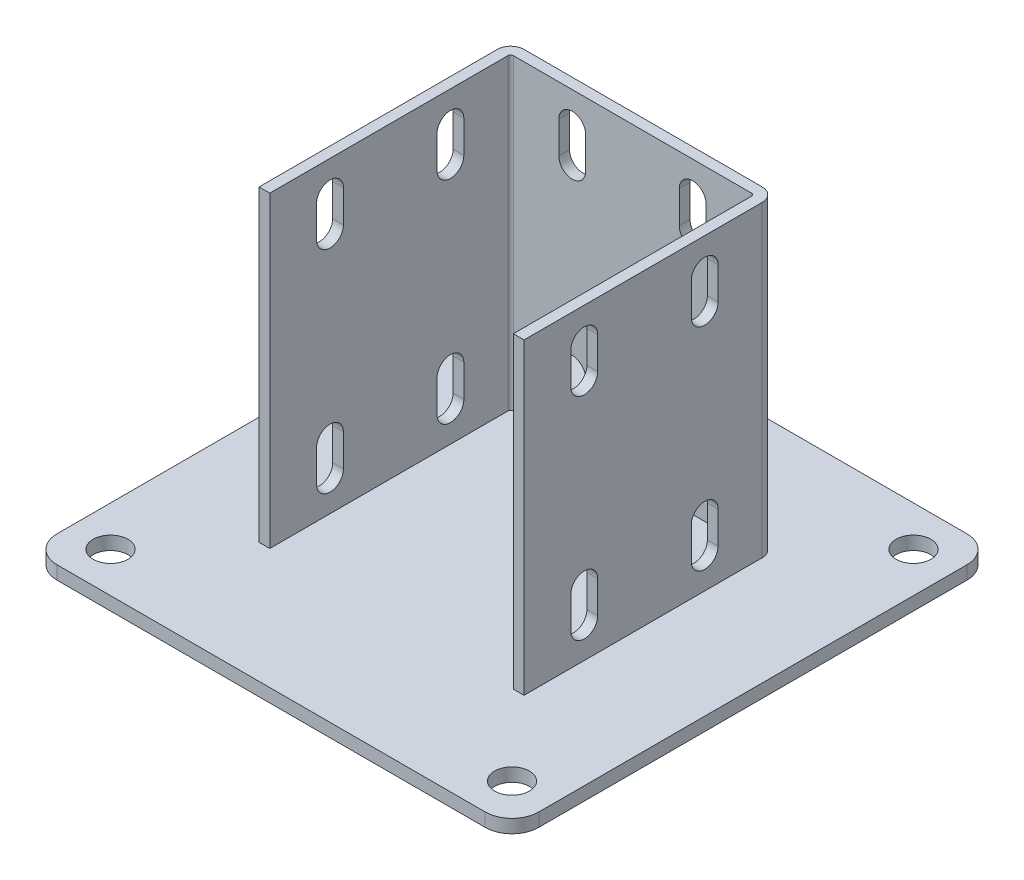
from build123d import *

# Parameters (mm, degrees)
SKETCH_2_W          = 180
SKETCH_2_H          = 180
EXTRUDE_1_DEPTH     = 5
EXTRUDE_1_2_DEPTH   = 115
EXTRUDE_2_DEPTH     = 2
CUT_EXTRUDE_1_DEPTH = 140.5
SKETCH_6_R          = 6.5
CUT_EXTRUDE_2_DEPTH = 6
FILLET_1_R          = 10
CUT_EXTRUDE_3_REACH = 141


with BuildPart() as part:
    # Эскиз2 → Extrude 1 (new body)
    with BuildSketch(Plane(origin=(0, 0, 0), x_dir=(1, 0, 0), z_dir=(0, 1, 0))):
        Rectangle(SKETCH_2_W, SKETCH_2_H)
    extrude(amount=EXTRUDE_1_DEPTH)

    # Эскиз3 → Extrude 1 2 (add)
    with BuildSketch(Plane(origin=(0, 5, 0), x_dir=(1, 0, 0), z_dir=(0, 1, 0))):
        with BuildLine():
            Line((-45.5, -45), (-45.5, 44))
            ThreePointArc((-45.5, 44), (-45.207106781, 44.707106781), (-44.5, 45))
            Line((-44.5, 45), (44.5, 45))
            ThreePointArc((44.5, 45), (45.207106781, 44.707106781), (45.5, 44))
            Line((45.5, 44), (45.5, -45))
            Line((45.5, -45), (49.5, -45))
            Line((49.5, -45), (49.5, 44))
            ThreePointArc((49.5, 44), (48.035533906, 47.535533906), (44.5, 49))
            Line((44.5, 49), (-44.5, 49))
            ThreePointArc((-44.5, 49), (-48.035533906, 47.535533906), (-49.5, 44))
            Line((-49.5, 44), (-49.5, -45))
            Line((-49.5, -45), (-45.5, -45))
        make_face()
    extrude(amount=EXTRUDE_1_2_DEPTH)

    # Эскиз4 → Бобышка-Вытянуть2 (add, symmetric)
    with BuildSketch(Plane(origin=(0, 0, 0), x_dir=(0, 0, -1), z_dir=(1, 0, 0))):
        Polygon((49, 67.353829072), (85, 5), (49, 5), align=None)
    extrude(amount=EXTRUDE_2_DEPTH, both=True)

    # Эскиз5 → Вырез-Вытянуть1 (cut, through all)
    with BuildSketch(Plane(origin=(49.5, 0, 0), x_dir=(0, 0, -1), z_dir=(1, 0, 0))):
        with BuildLine():
            Line((-17.5, 108), (-17.5, 96))
            ThreePointArc((-17.5, 96), (-22.5, 91), (-27.5, 96))
            Line((-27.5, 96), (-27.5, 108))
            ThreePointArc((-27.5, 108), (-22.5, 113), (-17.5, 108))
        make_face()
        with BuildLine():
            Line((-17.5, 29), (-17.5, 17))
            ThreePointArc((-17.5, 17), (-22.5, 12), (-27.5, 17))
            Line((-27.5, 17), (-27.5, 29))
            ThreePointArc((-27.5, 29), (-22.5, 34), (-17.5, 29))
        make_face()
        with BuildLine():
            Line((17.5, 108), (17.5, 96))
            ThreePointArc((17.5, 96), (22.5, 91), (27.5, 96))
            Line((27.5, 96), (27.5, 108))
            ThreePointArc((27.5, 108), (22.5, 113), (17.5, 108))
        make_face()
        with BuildLine():
            Line((17.5, 29), (17.5, 17))
            ThreePointArc((17.5, 17), (22.5, 12), (27.5, 17))
            Line((27.5, 17), (27.5, 29))
            ThreePointArc((27.5, 29), (22.5, 34), (17.5, 29))
        make_face()
    extrude(amount=-CUT_EXTRUDE_1_DEPTH, mode=Mode.SUBTRACT)

    # Эскиз6 → Вырез-Вытянуть2 (cut, through all)
    with BuildSketch(Plane(origin=(0, 5, 0), x_dir=(1, 0, 0), z_dir=(0, 1, 0))):
        with Locations(Location((-75, 75, 0), (0, 0, 270))):  # turned: the seam where the file's is
            Circle(SKETCH_6_R)
        with Locations(Location((-75, -75, 0), (0, 0, 270))):  # turned: the seam where the file's is
            Circle(SKETCH_6_R)
        with Locations(Location((75, 75, 0), (0, 0, 270))):  # turned: the seam where the file's is
            Circle(SKETCH_6_R)
        with Locations(Location((75, -75, 0), (0, 0, 270))):  # turned: the seam where the file's is
            Circle(SKETCH_6_R)
    extrude(amount=-CUT_EXTRUDE_2_DEPTH, mode=Mode.SUBTRACT)

    # Скругление1
    fillet_1_edges = [part.edges().sort_by_distance(p)[0] for p in [
        (90, 2.5, 90),
        (-90, 2.5, 90),
        (-90, 2.5, -90),
        (90, 2.5, -90),
    ]]
    fillet(fillet_1_edges, radius=FILLET_1_R)

    # Эскиз8 → Вырез-Вытянуть3 (cut, up to next)
    with BuildSketch(Plane(origin=(0, 0, -49), x_dir=(-1, 0, 0), z_dir=(0, 0, -1)), mode=Mode.PRIVATE) as cut_extrude_3_sk1:
        with BuildLine():
            Line((-17.5, 108), (-17.5, 96))
            ThreePointArc((-17.5, 96), (-22.5, 91), (-27.5, 96))
            Line((-27.5, 96), (-27.5, 108))
            ThreePointArc((-27.5, 108), (-22.5, 113), (-17.5, 108))
        make_face()
    cut_extrude_3_tool1 = extrude(cut_extrude_3_sk1.sketch, amount=-CUT_EXTRUDE_3_REACH, mode=Mode.PRIVATE) & part.part
    add(cut_extrude_3_tool1.solids().sort_by_distance((22.5, 102, -49))[0], mode=Mode.SUBTRACT)
    # Эскиз8 → Вырез-Вытянуть3 (cut, up to next)
    with BuildSketch(Plane(origin=(0, 0, -49), x_dir=(-1, 0, 0), z_dir=(0, 0, -1)), mode=Mode.PRIVATE) as cut_extrude_3_sk2:
        with BuildLine():
            Line((-17.5, 29), (-17.5, 17))
            ThreePointArc((-17.5, 17), (-22.5, 12), (-27.5, 17))
            Line((-27.5, 17), (-27.5, 29))
            ThreePointArc((-27.5, 29), (-22.5, 34), (-17.5, 29))
        make_face()
    cut_extrude_3_tool2 = extrude(cut_extrude_3_sk2.sketch, amount=-CUT_EXTRUDE_3_REACH, mode=Mode.PRIVATE) & part.part
    add(cut_extrude_3_tool2.solids().sort_by_distance((22.5, 23, -49))[0], mode=Mode.SUBTRACT)
    # Эскиз8 → Вырез-Вытянуть3 (cut, up to next)
    with BuildSketch(Plane(origin=(0, 0, -49), x_dir=(-1, 0, 0), z_dir=(0, 0, -1)), mode=Mode.PRIVATE) as cut_extrude_3_sk3:
        with BuildLine():
            Line((17.5, 108), (17.5, 96))
            ThreePointArc((17.5, 96), (22.5, 91), (27.5, 96))
            Line((27.5, 96), (27.5, 108))
            ThreePointArc((27.5, 108), (22.5, 113), (17.5, 108))
        make_face()
    cut_extrude_3_tool3 = extrude(cut_extrude_3_sk3.sketch, amount=-CUT_EXTRUDE_3_REACH, mode=Mode.PRIVATE) & part.part
    add(cut_extrude_3_tool3.solids().sort_by_distance((-22.5, 102, -49))[0], mode=Mode.SUBTRACT)
    # Эскиз8 → Вырез-Вытянуть3 (cut, up to next)
    with BuildSketch(Plane(origin=(0, 0, -49), x_dir=(-1, 0, 0), z_dir=(0, 0, -1)), mode=Mode.PRIVATE) as cut_extrude_3_sk4:
        with BuildLine():
            Line((17.5, 29), (17.5, 17))
            ThreePointArc((17.5, 17), (22.5, 12), (27.5, 17))
            Line((27.5, 17), (27.5, 29))
            ThreePointArc((27.5, 29), (22.5, 34), (17.5, 29))
        make_face()
    cut_extrude_3_tool4 = extrude(cut_extrude_3_sk4.sketch, amount=-CUT_EXTRUDE_3_REACH, mode=Mode.PRIVATE) & part.part
    add(cut_extrude_3_tool4.solids().sort_by_distance((-22.5, 23, -49))[0], mode=Mode.SUBTRACT)


solid = part.part
